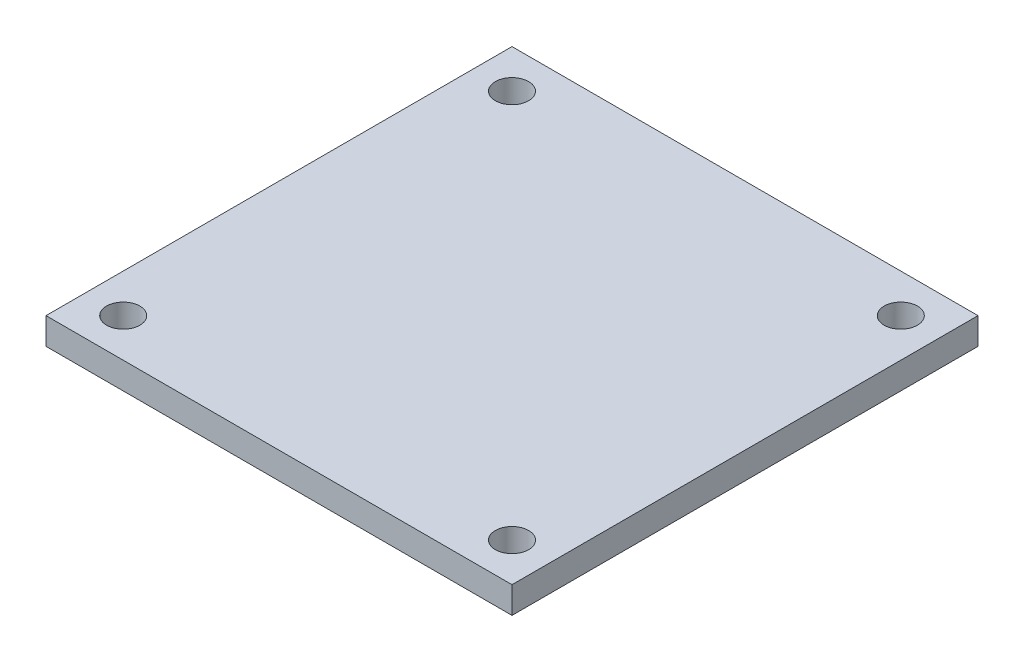
from build123d import *

# Parameters (mm, degrees)
SKETCH1_W           = 35
SKETCH1_H           = 35
BOSS_EXTRUDE1_DEPTH = 2
SKETCH2_R           = 1.25
CUT_EXTRUDE1_DEPTH  = 3


with BuildPart() as part:
    # Sketch1 → Boss-Extrude1 (new body)
    with BuildSketch(Plane(origin=(0, 0, 0), x_dir=(1, 0, 0), z_dir=(0, 1, 0))):
        Rectangle(SKETCH1_W, SKETCH1_H)
    extrude(amount=BOSS_EXTRUDE1_DEPTH)

    # Sketch2 → Cut-Extrude1 (cut, through all)
    with BuildSketch(Plane(origin=(0, 2, 0), x_dir=(1, 0, 0), z_dir=(0, 1, 0))):
        with Locations((14.6, -14.6)):
            Circle(SKETCH2_R)
        with Locations((-14.6, -14.6)):
            Circle(SKETCH2_R)
        with Locations((-14.6, 14.6)):
            Circle(SKETCH2_R)
        with Locations((14.6, 14.6)):
            Circle(SKETCH2_R)
    extrude(amount=-CUT_EXTRUDE1_DEPTH, mode=Mode.SUBTRACT)


solid = part.part
